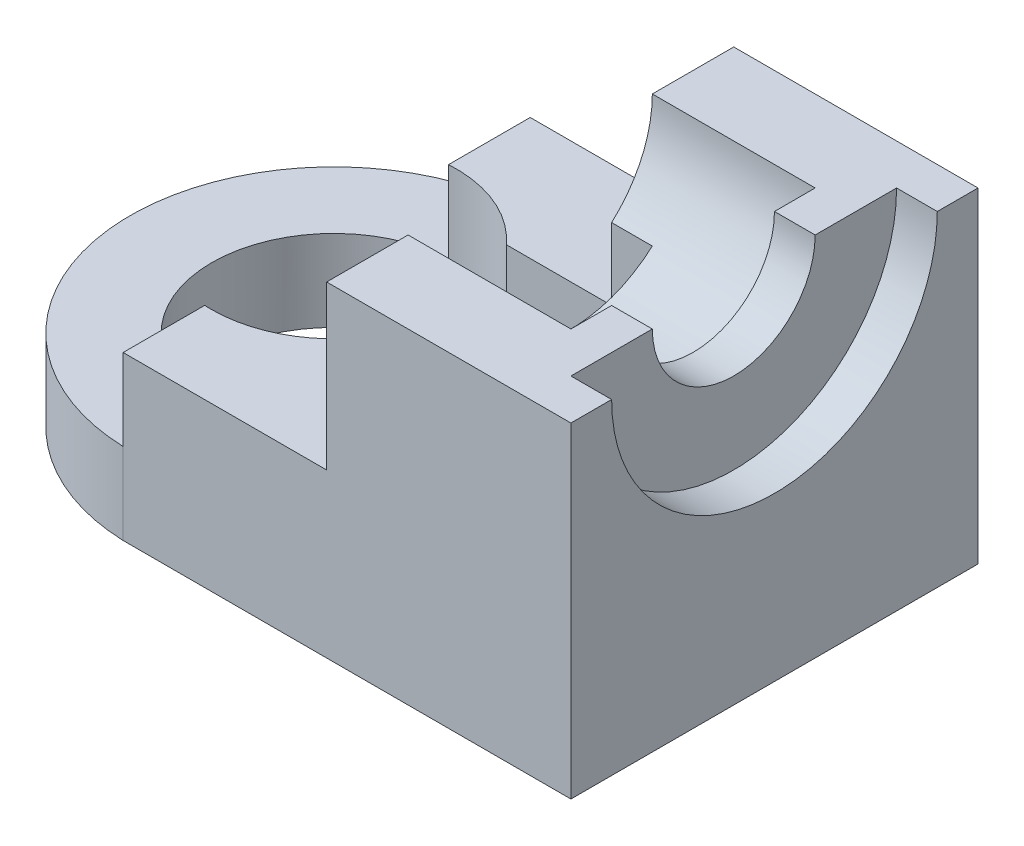
from build123d import *

# Parameters (mm, degrees)
BOSS_EXTRUDE1_DEPTH     = 16
SKETCH2_R               = 3
CUT_EXTRUDE1_DEPTH      = 18
SKETCH3_R               = 4
CUT_EXTRUDE2_DEPTH      = 1
SKETCH4_R               = 3
CUT_EXTRUDE3_DEPTH      = 14
SKETCH5_W               = 6.803133859
SKETCH5_H               = 10.102230074
CUT_EXTRUDE4_DEPTH      = 6
SKETCH6_W               = 5
SKETCH6_H               = 10
CUT_EXTRUDE5_DEPTH      = 4
SKETCH7_W               = 6.342903926
SKETCH7_H               = 4
CUT_EXTRUDE6_DEPTH      = 4
CUT_EXTRUDE6_DEPTH_BACK = 2


with BuildPart() as part:
    # Sketch1 → Boss-Extrude1 (new body)
    with BuildSketch(Plane(origin=(0, 0, 0), x_dir=(0, 0, -1), z_dir=(1, 0, 0))):
        with BuildLine():
            Line((-2, 4), (-5, 4))
            Line((-5, 4), (-5, -4))
            Line((-5, -4), (5, -4))
            Line((5, -4), (5, 4))
            Line((5, 4), (2, 4))
            ThreePointArc((2, 4), (0, 2), (-2, 4))
        make_face()
    extrude(amount=BOSS_EXTRUDE1_DEPTH)

    # Sketch2 → Cut-Extrude1 (cut)
    with BuildSketch(Plane(origin=(0, 4, 0), x_dir=(1, 0, 0), z_dir=(0, 1, 0))):
        with Locations((5.17622925, 0)):
            Circle(SKETCH2_R)
        with BuildLine():
            Line((5, 5), (0, 5))
            Line((0, 5), (0, -5))
            Line((0, -5), (5, -5))
            ThreePointArc((5, -5), (0.173124539, 0), (5, 5))
        make_face()
    extrude(amount=-CUT_EXTRUDE1_DEPTH, mode=Mode.SUBTRACT)

    # Sketch3 → Cut-Extrude2 (cut)
    with BuildSketch(Plane(origin=(16, 0, 0), x_dir=(0, 0, -1), z_dir=(1, 0, 0))):
        with Locations((0, 4)):
            Circle(SKETCH3_R)
    extrude(amount=-CUT_EXTRUDE2_DEPTH, mode=Mode.SUBTRACT)

    # Sketch4 → Cut-Extrude3 (cut)
    with BuildSketch(Plane(origin=(0, 0, 0), x_dir=(0, 0, -1), z_dir=(1, 0, 0))):
        with Locations((0, 4)):
            Circle(SKETCH4_R)
    extrude(amount=CUT_EXTRUDE3_DEPTH, mode=Mode.SUBTRACT)

    # Sketch5 → Cut-Extrude4 (cut)
    with BuildSketch(Plane(origin=(0, 4, 0), x_dir=(1, 0, 0), z_dir=(0, 1, 0))):
        with Locations((1.598433071, -0.051115037)):
            Rectangle(SKETCH5_W, SKETCH5_H)
    extrude(amount=-CUT_EXTRUDE4_DEPTH, mode=Mode.SUBTRACT)

    # Sketch6 → Cut-Extrude5 (cut)
    with BuildSketch(Plane(origin=(0, 4, 0), x_dir=(1, 0, 0), z_dir=(0, 1, 0))):
        with Locations((7.5, 0)):
            Rectangle(SKETCH6_W, SKETCH6_H)
    extrude(amount=-CUT_EXTRUDE5_DEPTH, mode=Mode.SUBTRACT)

    # Sketch7 → Cut-Extrude6 (cut, two sides)
    with BuildSketch(Plane(origin=(0, 0, 0), x_dir=(1, 0, 0), z_dir=(0, 1, 0))) as cut_extrude6_sk:
        with Locations((7.828548037, 0)):
            Rectangle(SKETCH7_W, SKETCH7_H)
    extrude(amount=CUT_EXTRUDE6_DEPTH, mode=Mode.SUBTRACT)
    extrude(cut_extrude6_sk.sketch, amount=-CUT_EXTRUDE6_DEPTH_BACK, mode=Mode.SUBTRACT)


solid = part.part
